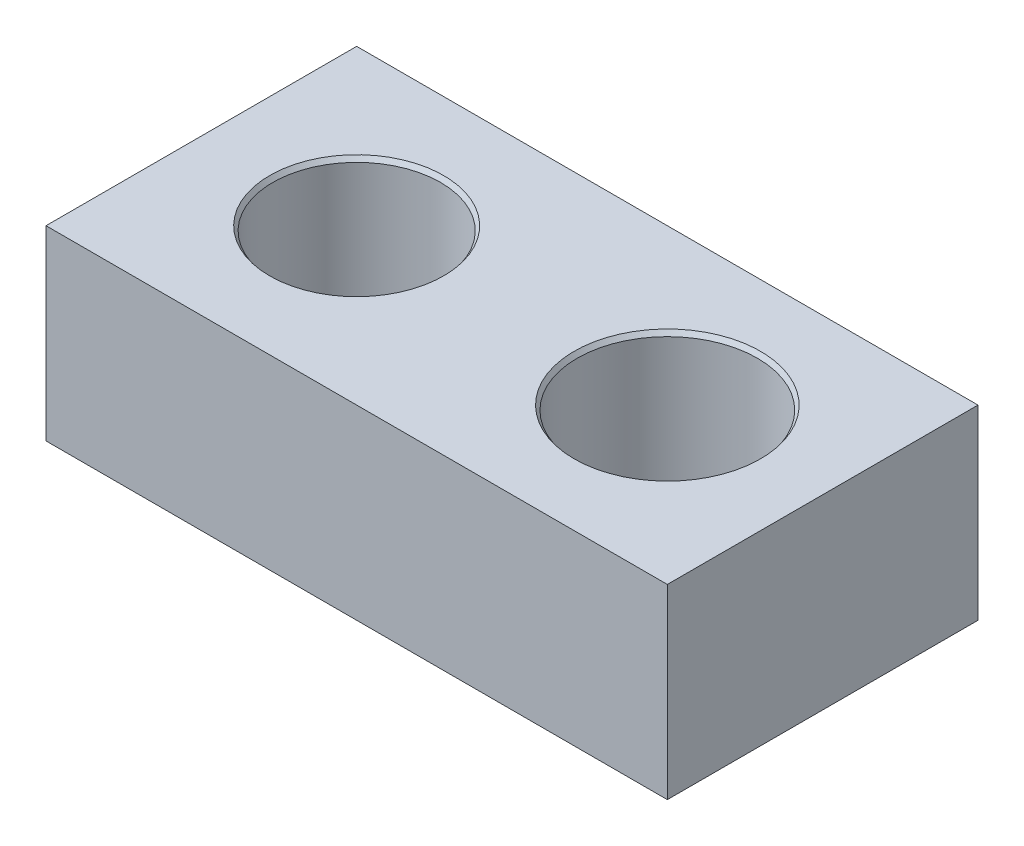
from build123d import *

# Parameters (mm, degrees)
SKETCH1_W                            = 20
SKETCH1_H                            = 10
BOSS_EXTRUDE1_DEPTH                  = 6
F_5_4_5_4_DIAMETER_HOLE1_D           = 5.4
F_5_4_5_4_DIAMETER_HOLE1_CSINK_D     = 5.6
F_5_4_5_4_DIAMETER_HOLE1_CSINK_ANGLE = 70
F_5_8_5_8_DIAMETER_HOLE1_D           = 5.8
F_5_8_5_8_DIAMETER_HOLE1_CSINK_D     = 6
F_5_8_5_8_DIAMETER_HOLE1_CSINK_ANGLE = 70


with BuildPart() as part:
    # Sketch1 → Boss-Extrude1 (new body)
    with BuildSketch(Plane(origin=(0, 0, 0), x_dir=(1, 0, 0), z_dir=(0, 1, 0))):
        with Locations((10, 5)):
            Rectangle(SKETCH1_W, SKETCH1_H)
    extrude(amount=BOSS_EXTRUDE1_DEPTH)

    # Ø5.4 (5.4) Diameter Hole1 (through all)
    with Locations(Plane(origin=(0, 6, 0), x_dir=(1, 0, 0), z_dir=(0, 1, 0))):
        with Locations((5, 5)):
            CounterSinkHole(F_5_4_5_4_DIAMETER_HOLE1_D / 2, F_5_4_5_4_DIAMETER_HOLE1_CSINK_D / 2, counter_sink_angle=F_5_4_5_4_DIAMETER_HOLE1_CSINK_ANGLE)

    # Ø5.8 (5.8) Diameter Hole1 (through all)
    with Locations(Plane(origin=(0, 6, 0), x_dir=(1, 0, 0), z_dir=(0, 1, 0))):
        with Locations((15, 5)):
            CounterSinkHole(F_5_8_5_8_DIAMETER_HOLE1_D / 2, F_5_8_5_8_DIAMETER_HOLE1_CSINK_D / 2, counter_sink_angle=F_5_8_5_8_DIAMETER_HOLE1_CSINK_ANGLE)


solid = part.part
